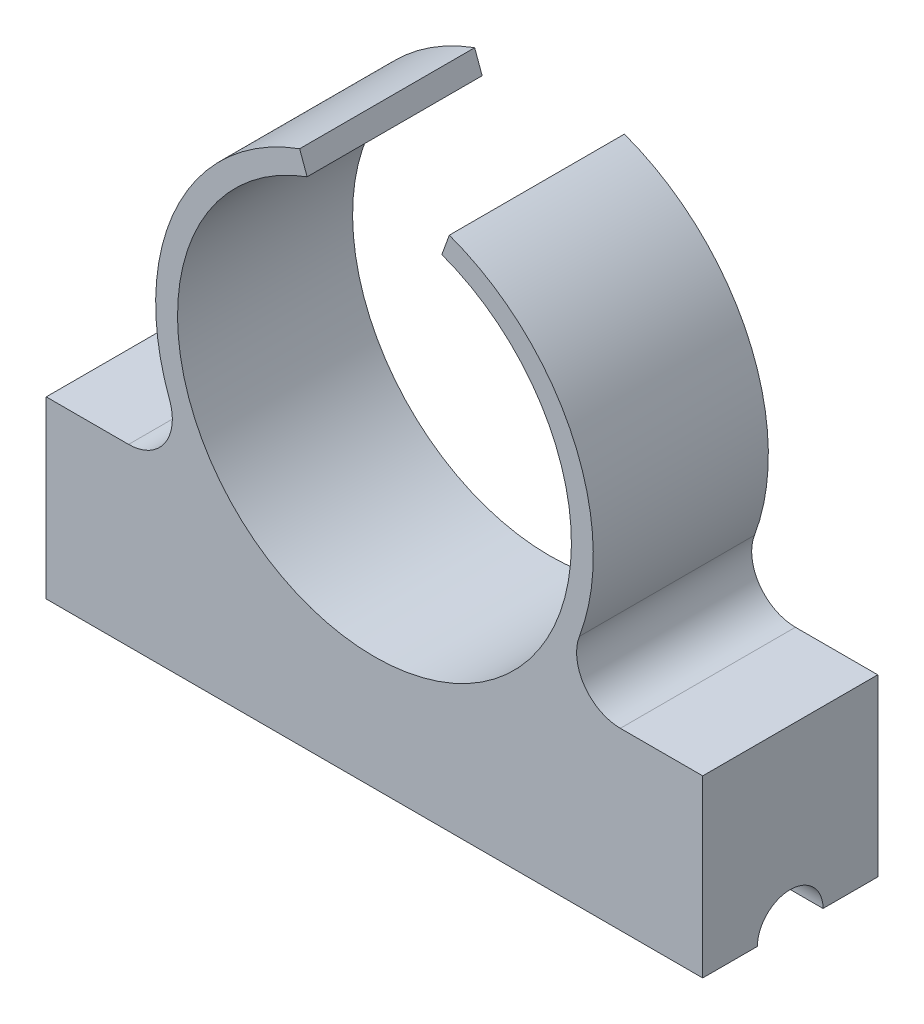
from build123d import *

# Parameters (mm, degrees)
BOSS_EXTRUDE1_DEPTH = 8
SKETCH2_R           = 9
CUT_EXTRUDE1_DEPTH  = 35
SKETCH3_W           = 0.5
SKETCH3_H           = 1.875425002
CUT_EXTRUDE2_DEPTH  = 25
SKETCH4_R           = 1.5
CUT_EXTRUDE3_DEPTH  = 110
SKETCH6_W           = 5
SKETCH6_H           = 7.147198513
CUT_EXTRUDE4_DEPTH  = 10
FILLET1_R           = 0.5
SKETCH8_W           = 8
SKETCH8_H           = 3
BOSS_EXTRUDE2_DEPTH = 30
SKETCH9_R           = 9
CUT_EXTRUDE5_DEPTH  = 30
FILLET2_R           = 2
CUT_EXTRUDE7_DEPTH  = 30


with BuildPart() as part:
    # Sketch1 → Boss-Extrude1 (new body)
    with BuildSketch(Plane.XY):
        with BuildLine():
            Line((3.89007335, 2.5), (15, 2.5))
            Line((15, 2.5), (15, -2.5))
            Line((15, -2.5), (-15, -2.5))
            Line((-15, -2.5), (-15, 2.5))
            Line((-15, 2.5), (-3.89007335, 2.5))
            ThreePointArc((-3.89007335, 2.5), (0, 21.71234657), (3.89007335, 2.5))
        make_face()
    extrude(amount=BOSS_EXTRUDE1_DEPTH)

    # Sketch2 → Cut-Extrude1 (cut)
    with BuildSketch(Plane.XY.offset(8)):
        with Locations((0, 11.71234657)):
            Circle(SKETCH2_R)
    extrude(amount=-CUT_EXTRUDE1_DEPTH, mode=Mode.SUBTRACT)

    # Sketch3 → Cut-Extrude2 (cut)
    with BuildSketch(Plane(origin=(0, 0, 0), x_dir=(-1, 0, 0), z_dir=(0, 0, -1))):
        with Locations((0, 21.521483579)):
            Rectangle(SKETCH3_W, SKETCH3_H)
    extrude(amount=-CUT_EXTRUDE2_DEPTH, mode=Mode.SUBTRACT)

    # Sketch4 → Cut-Extrude3 (cut)
    with BuildSketch(Plane(origin=(15, 0, 0), x_dir=(0, 0, -1), z_dir=(1, 0, 0))):
        with Locations((-4, -2.5)):
            Circle(SKETCH4_R)
    extrude(amount=-CUT_EXTRUDE3_DEPTH, mode=Mode.SUBTRACT)

    # Sketch6 → Cut-Extrude4 (cut)
    with BuildSketch(Plane.XY.offset(8)):
        with Locations((0, 22.731746569)):
            Rectangle(SKETCH6_W, SKETCH6_H)
    extrude(amount=-CUT_EXTRUDE4_DEPTH, mode=Mode.SUBTRACT)

    # Fillet1
    fillet1_edges = [part.edges().sort_by_distance(p)[0] for p in [
        (-3.89007335, 2.5, 4),
        (3.89007335, 2.5, 4),
    ]]
    fillet(fillet1_edges, radius=FILLET1_R)

    # Sketch8 → Boss-Extrude2 (add)
    with BuildSketch(Plane.ZY.offset(15)):
        with Locations((4, 4)):
            Rectangle(SKETCH8_W, SKETCH8_H)
    extrude(amount=-BOSS_EXTRUDE2_DEPTH)

    # Sketch9 → Cut-Extrude5 (cut)
    with BuildSketch(Plane(origin=(0, 0, 0), x_dir=(-1, 0, 0), z_dir=(0, 0, -1))):
        with Locations((0, 11.71234657)):
            Circle(SKETCH9_R)
    extrude(amount=-CUT_EXTRUDE5_DEPTH, mode=Mode.SUBTRACT)

    # Fillet2
    fillet2_edges = [part.edges().sort_by_distance(p)[0] for p in [
        (-7.836245918, 5.5, 4),
        (7.836245918, 5.5, 4),
    ]]
    fillet(fillet2_edges, radius=FILLET2_R)

    # Sketch10 → Cut-Extrude7 (cut)
    with BuildSketch(Plane(origin=(0, 0, 0), x_dir=(-1, 0, 0), z_dir=(0, 0, -1))):
        with BuildLine():
            Line((0, 11.71234657), (3.420201433, 21.109272778))
            ThreePointArc((3.420201433, 21.109272778), (0, 24.529474212), (-3.420201433, 21.109272778))
            Line((-3.420201433, 21.109272778), (0, 11.71234657))
        make_face()
    extrude(amount=-CUT_EXTRUDE7_DEPTH, mode=Mode.SUBTRACT)


solid = part.part
